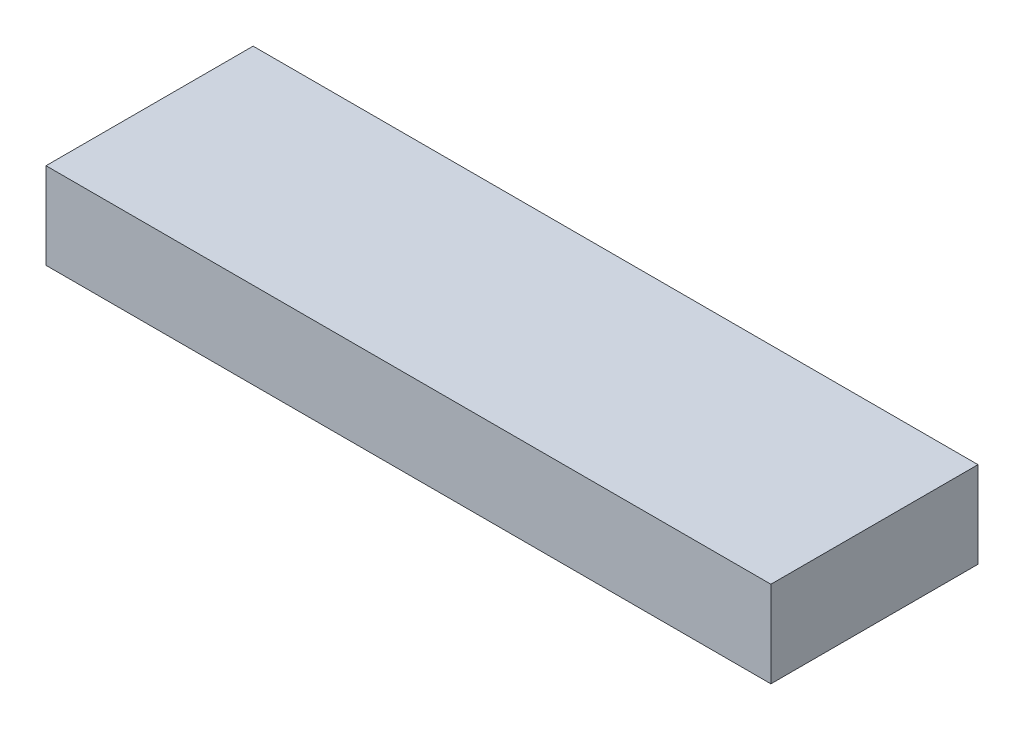
from build123d import *

# Parameters (mm, degrees)
SKETCH1_W           = 210
SKETCH1_H           = 60
BOSS_EXTRUDE1_DEPTH = 25


with BuildPart() as part:
    # Sketch1 → Boss-Extrude1 (new body)
    with BuildSketch(Plane(origin=(0, 0, 0), x_dir=(1, 0, 0), z_dir=(0, 1, 0))):
        Rectangle(SKETCH1_W, SKETCH1_H)
    extrude(amount=BOSS_EXTRUDE1_DEPTH)


solid = part.part
